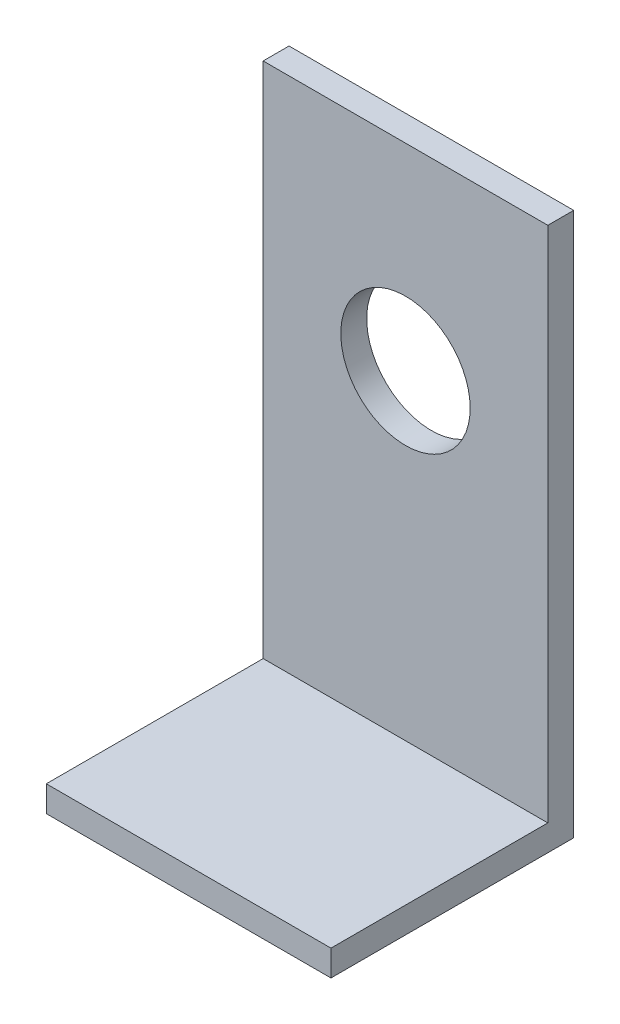
from build123d import *

# Parameters (mm, degrees)
CROQUIS1_R              = 12.5
SALIENTE_EXTRUIR1_DEPTH = 5
CROQUIS2_W              = 55
CROQUIS2_H              = 5
SALIENTE_EXTRUIR2_DEPTH = 41.9


with BuildPart() as part:
    # Croquis1 → Saliente-Extruir1 (new body)
    with BuildSketch(Plane.XY):
        Polygon((0, 105), (27.5, 105), (27.5, 0), (-27.5, 0), (-27.5, 105), align=None)
        with Locations((0, 66.9)):
            Circle(CROQUIS1_R, mode=Mode.SUBTRACT)
    extrude(amount=SALIENTE_EXTRUIR1_DEPTH)

    # Croquis2 → Saliente-Extruir2 (add)
    with BuildSketch(Plane.XY.offset(5)):
        with Locations((0, 2.5)):
            Rectangle(CROQUIS2_W, CROQUIS2_H)
    extrude(amount=SALIENTE_EXTRUIR2_DEPTH)


solid = part.part
